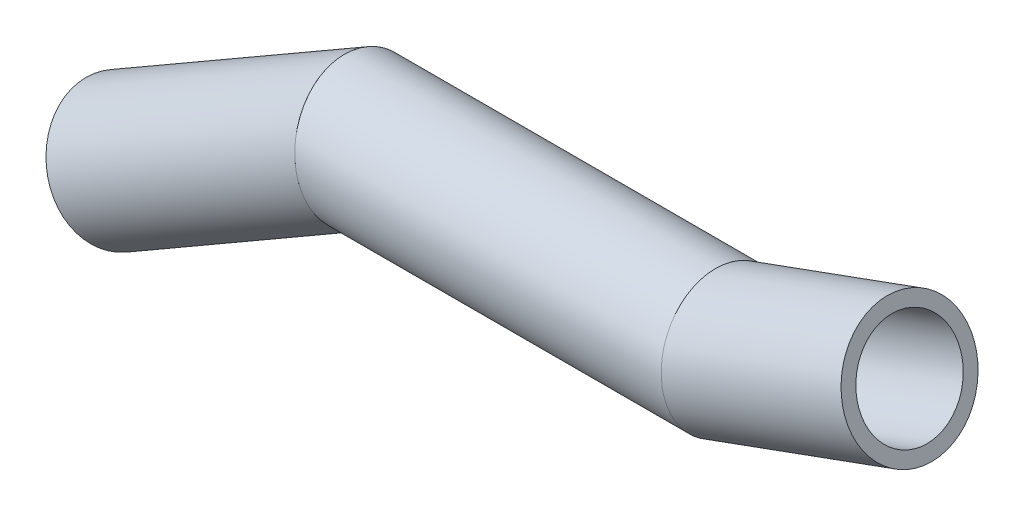
from build123d import *

# Parameters (mm, degrees)
SKETCH1_R                    = 10.65
SKETCH1_R_2                  = 8.35
TUBER_A_21_3_X_2_3_1_DEPTH   = 51.223704653
SKETCH1_ON_SEGMENT_2_R       = 10.65
SKETCH1_ON_SEGMENT_2_R_2     = 8.35
TUBER_A_21_3_X_2_3_1_2_DEPTH = 68.691409798
SKETCH1_ON_SEGMENT_3_R       = 10.65
SKETCH1_ON_SEGMENT_3_R_2     = 8.35
TUBER_A_21_3_X_2_3_1_3_DEPTH = 35.581059854


with BuildPart() as part:
    # Sketch1 → Tubería 21.3 X 2.3(1) (new body)
    with BuildSketch(Plane(origin=(0, 0, 0), x_dir=(-0.5, 0.866025404, 0), z_dir=(0.866025404, 0.5, 0))):
        Circle(SKETCH1_R)
        Circle(SKETCH1_R_2, mode=Mode.SUBTRACT)
    extrude(amount=TUBER_A_21_3_X_2_3_1_DEPTH)

    # Tubería 21.3 X 2.3(1) mitre 1
    split(bisect_by=Plane(origin=(40, 23.094010768, 0), x_dir=(0.258819045, -0.965925826, 0), z_dir=(-0.965925826, -0.258819045, 0)), keep=Keep.TOP)


with BuildPart() as body_2:
    # Sketch1 on segment 2 (carried to segment 2) → Tuber_a 21.3 X 2.3_1 2 (new body)
    with BuildSketch(Plane(origin=(34.964316882, 23.094010768, 0), x_dir=(0, 1, 0), z_dir=(1, 0, 0))):
        Circle(SKETCH1_ON_SEGMENT_2_R)
        Circle(SKETCH1_ON_SEGMENT_2_R_2, mode=Mode.SUBTRACT)
    extrude(amount=TUBER_A_21_3_X_2_3_1_2_DEPTH)

    # Tuber_a 21.3 X 2.3_1 2 mitre 1
    split(bisect_by=Plane(origin=(40, 23.094010768, 0), x_dir=(-0.258819045, 0.965925826, 0), z_dir=(0.965925826, 0.258819045, 0)), keep=Keep.TOP)

    # Tuber_a 21.3 X 2.3_1 2 mitre 2
    split(bisect_by=Plane(origin=(100, 23.094010768, 0), x_dir=(0.173648178, -0.984807753, 0), z_dir=(-0.984807753, -0.173648178, 0)), keep=Keep.TOP)


with BuildPart() as body_3:
    # Sketch1 on segment 3 (carried to segment 3) → Tuber_a 21.3 X 2.3_1 3 (new body)
    with BuildSketch(Plane(origin=(96.564740615, 21.843678604, 0), x_dir=(-0.342020143, 0.939692621, 0), z_dir=(0.939692621, 0.342020143, 0))):
        Circle(SKETCH1_ON_SEGMENT_3_R)
        Circle(SKETCH1_ON_SEGMENT_3_R_2, mode=Mode.SUBTRACT)
    extrude(amount=TUBER_A_21_3_X_2_3_1_3_DEPTH)

    # Tuber_a 21.3 X 2.3_1 3 mitre 1
    split(bisect_by=Plane(origin=(100, 23.094010768, 0), x_dir=(-0.173648178, 0.984807753, 0), z_dir=(0.984807753, 0.173648178, 0)), keep=Keep.TOP)


solid = Compound([part.part, body_2.part, body_3.part])
